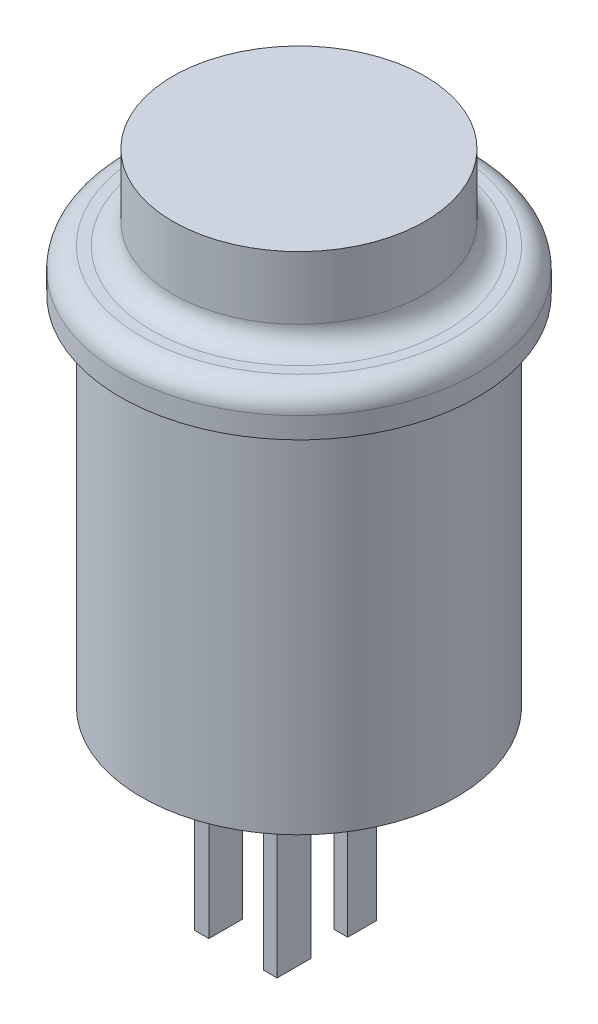
from build123d import *

# Parameters (mm, degrees)
IZIM1_R                     = 6
Y_KSEKLIK_EKSTR_ZYON1_DEPTH = 4
IZIM2_R                     = 8.5
Y_KSEKLIK_EKSTR_ZYON2_DEPTH = 2
RADYUS1_R                   = 1
IZIM3_R                     = 7.5
Y_KSEKLIK_EKSTR_ZYON3_DEPTH = 17
IZIM4_W                     = 0.657456129
IZIM4_H                     = 1.607114982
IZIM4_W_2                   = 0.693981469
IZIM4_H_2                   = 1.369700268
Y_KSEKLIK_EKSTR_ZYON4_DEPTH = 7


with BuildPart() as part:
    # Çizim1 → Yükseklik-Ekstrüzyon1 (new body)
    with BuildSketch(Plane(origin=(0, 0, 0), x_dir=(1, 0, 0), z_dir=(0, 1, 0))):
        Circle(IZIM1_R)
    extrude(amount=Y_KSEKLIK_EKSTR_ZYON1_DEPTH)

    # Çizim2 → Yükseklik-Ekstrüzyon2 (add)
    with BuildSketch(Plane.XZ):
        Circle(IZIM2_R)
    extrude(amount=Y_KSEKLIK_EKSTR_ZYON2_DEPTH)

    # Radyus1
    radyus1_edges = [part.edges().sort_by_distance(p)[0] for p in [
        (-8.5, 0, 0),
        (-6, 0, 0),
    ]]
    fillet(radyus1_edges, radius=RADYUS1_R)

    # Çizim3 → Yükseklik-Ekstrüzyon3 (add)
    with BuildSketch(Plane.XZ.offset(2)):
        Circle(IZIM3_R)
    extrude(amount=Y_KSEKLIK_EKSTR_ZYON3_DEPTH)

    # Çizim4 → Yükseklik-Ekstrüzyon4 (add)
    with BuildSketch(Plane.XZ.offset(19)):
        with Locations((3.360331326, 3.926474103)):
            Rectangle(IZIM4_W, IZIM4_H)
        with Locations((0.091313352, 3.926474103)):
            Rectangle(IZIM4_W_2, IZIM4_H)
        with Locations((3.360331326, 0.684850134)):
            Rectangle(IZIM4_W, IZIM4_H_2)
        with Locations((0.091313352, 0.684850134)):
            Rectangle(IZIM4_W_2, IZIM4_H_2)
    extrude(amount=Y_KSEKLIK_EKSTR_ZYON4_DEPTH)


solid = part.part
